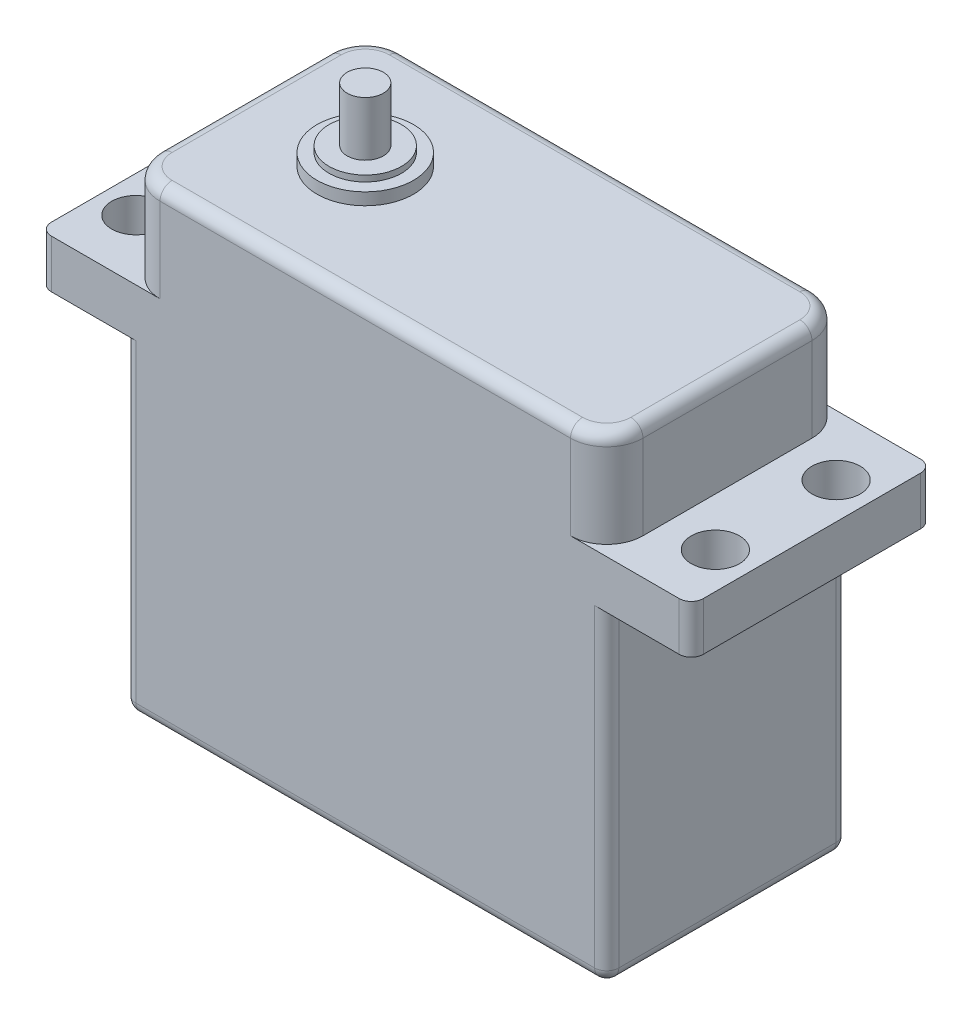
from build123d import *

# Parameters (mm, degrees)
SKETCH_1_W          = 40
SKETCH_1_H          = 39
SKETCH_1_R          = 2
EXTRUDE_2_DEPTH     = 20
SKETCH_4_R          = 2
CUT_EXTRUDE_1_DEPTH = 20
SKETCH_5_R          = 4
EXTRUDE_3_DEPTH     = 1
SKETCH_6_R          = 3
EXTRUDE_4_DEPTH     = 0.5
SKETCH_7_R          = 1.5
EXTRUDE_5_DEPTH     = 4.5
FILLET_2_R          = 3
FILLET_3_R          = 3
FILLET_4_R          = 1
FILLET_5_R          = 1
FILLET_6_R          = 1
FILLET_8_R          = 1


with BuildPart() as part:
    # 草图1 → 凸台-拉伸2 (new body)
    with BuildSketch(Plane.XY):
        Rectangle(SKETCH_1_W, SKETCH_1_H)
        with BuildLine():
            Line((-20, 7.5), (-20, 11.5))
            Line((-20, 11.5), (-24, 11.5))
            ThreePointArc((-24, 11.5), (-22.585786438, 10.914213562), (-22, 9.5))
            ThreePointArc((-22, 9.5), (-22.585786438, 8.085786438), (-24, 7.5))
            Line((-24, 7.5), (-20, 7.5))
        make_face()
        with BuildLine():
            ThreePointArc((-24, 7.5), (-26, 9.5), (-24, 11.5))
            Line((-24, 11.5), (-27, 11.5))
            Line((-27, 11.5), (-27, 7.5))
            Line((-27, 7.5), (-24, 7.5))
        make_face()
        with Locations((-24, 9.5)):
            Circle(SKETCH_1_R)
        Polygon((27, 11.5), (20, 11.5), (20, 7.5), (24, 7.5), (27, 7.5), align=None)
    extrude(amount=EXTRUDE_2_DEPTH)

    # 草图4 → 切除-拉伸1 (cut)
    with BuildSketch(Plane(origin=(0, 19.5, 0), x_dir=(1, 0, 0), z_dir=(0, 1, 0))):
        with Locations((-24, -15)):
            Circle(SKETCH_4_R)
        with Locations((24, -15)):
            Circle(SKETCH_4_R)
        with Locations((-24, -5)):
            Circle(SKETCH_4_R)
        with Locations((24, -5)):
            Circle(SKETCH_4_R)
    extrude(amount=-CUT_EXTRUDE_1_DEPTH, mode=Mode.SUBTRACT)

    # 草图5 → 凸台-拉伸3 (add)
    with BuildSketch(Plane(origin=(0, 19.5, 0), x_dir=(1, 0, 0), z_dir=(0, 1, 0))):
        with Locations((-10, -10)):
            Circle(SKETCH_5_R)
    extrude(amount=EXTRUDE_3_DEPTH)

    # 草图6 → 凸台-拉伸4 (add)
    with BuildSketch(Plane(origin=(0, 20.5, 0), x_dir=(1, 0, 0), z_dir=(0, 1, 0))):
        with Locations((-10, -10)):
            Circle(SKETCH_6_R)
    extrude(amount=EXTRUDE_4_DEPTH)

    # 草图7 → 凸台-拉伸5 (add)
    with BuildSketch(Plane(origin=(0, 21, 0), x_dir=(1, 0, 0), z_dir=(0, 1, 0))):
        with Locations((-10, -10)):
            Circle(SKETCH_7_R)
    extrude(amount=EXTRUDE_5_DEPTH)

    # 圆角2
    fillet_2_edges = [part.edges().sort_by_distance(p)[0] for p in [
        (-20, 15.5, 20),
    ]]
    fillet(fillet_2_edges, radius=FILLET_2_R)

    # 圆角3
    fillet_3_edges = [part.edges().sort_by_distance(p)[0] for p in [
        (-20, 15.5, 0),
        (20, 15.5, 0),
        (20, 15.5, 20),
    ]]
    fillet(fillet_3_edges, radius=FILLET_3_R)

    # 圆角4
    fillet_4_edges = [part.edges().sort_by_distance(p)[0] for p in [
        (20, -6, 0),
        (0, -19.5, 0),
        (-20, -6, 0),
        (20, -19.5, 10),
        (-20, -19.5, 10),
        (-20, -6, 20),
        (0, -19.5, 20),
        (20, -6, 20),
    ]]
    fillet(fillet_4_edges, radius=FILLET_4_R)

    # 圆角5
    fillet_5_edges = [part.edges().sort_by_distance(p)[0] for p in [
        (-27, 9.5, 0),
        (-27, 9.5, 20),
    ]]
    fillet(fillet_5_edges, radius=FILLET_5_R)

    # 圆角6
    fillet_6_edges = [part.edges().sort_by_distance(p)[0] for p in [
        (19.121320344, 19.5, 0.878679656),
        (19.121320344, 19.5, 19.121320344),
        (0, 19.5, 20),
        (-20, 19.5, 10),
        (-19.121320344, 19.5, 19.121320344),
        (20, 19.5, 10),
        (0, 19.5, 0),
        (-19.121320344, 19.5, 0.878679656),
    ]]
    fillet(fillet_6_edges, radius=FILLET_6_R)

    # 圆角8
    fillet_8_edges = [part.edges().sort_by_distance(p)[0] for p in [
        (27, 9.5, 0),
        (27, 9.5, 20),
    ]]
    fillet(fillet_8_edges, radius=FILLET_8_R)


solid = part.part
